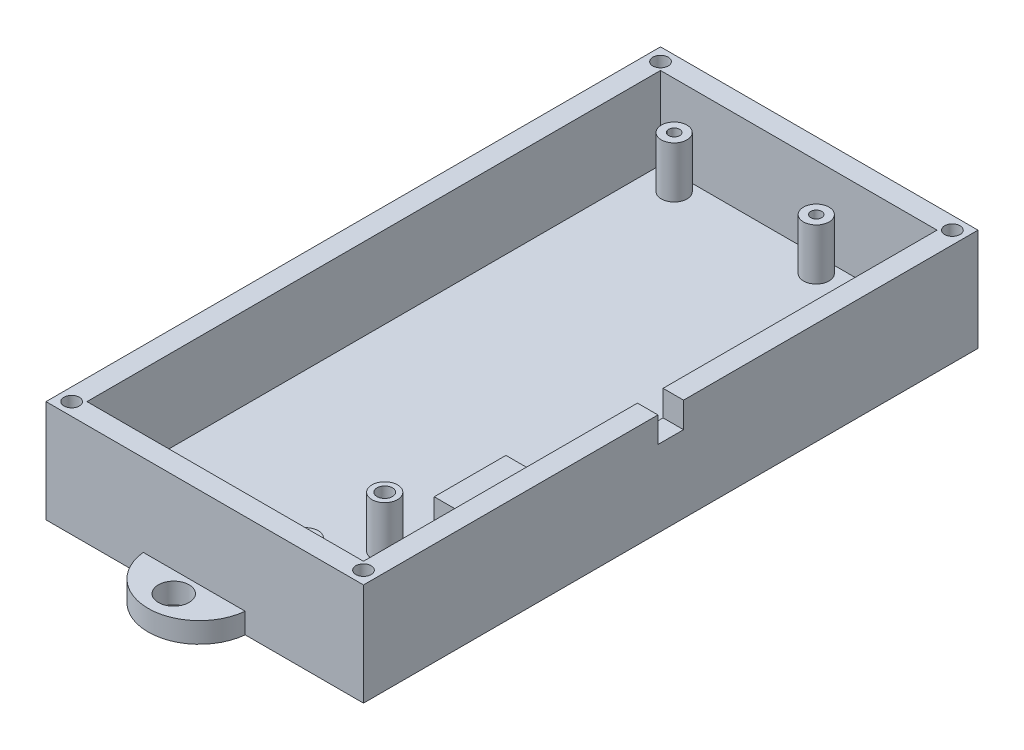
from build123d import *

# Parameters (mm, degrees)
SKETCH1_W                      = 60
SKETCH1_H                      = 118
BOSS_EXTRUDE1_DEPTH            = 4
SKETCH2_R                      = 2.5
BOSS_EXTRUDE2_DEPTH            = 10
SKETCH3_R                      = 1.075
SKETCH3_R_2                    = 1.5
CUT_EXTRUDE1_DEPTH             = 8
SKETCH4_W                      = 14
SKETCH4_H                      = 14
BOSS_EXTRUDE3_DEPTH            = 5
SKETCH5_W                      = 60
SKETCH5_H                      = 118
SKETCH5_W_2                    = 54
SKETCH5_H_2                    = 112
BOSS_EXTRUDE4_DEPTH            = 16
SKETCH10_W                     = 62
SKETCH10_H                     = 120
SKETCH10_W_2                   = 60
SKETCH10_H_2                   = 118
BOSS_EXTRUDE7_DEPTH            = 20
SKETCH6_R                      = 1.5
CUT_EXTRUDE2_DEPTH             = 10
CUT_EXTRUDE3_REACH             = 63
SKETCH7_W                      = 5
SKETCH7_H                      = 10
CUT_EXTRUDE3_DIRECTION_2_DEPTH = 10
SKETCH8_R                      = 3
BOSS_EXTRUDE5_DEPTH            = 4


with BuildPart() as part:
    # Sketch1 → Boss-Extrude1 (new body)
    with BuildSketch(Plane(origin=(0, 0, 0), x_dir=(1, 0, 0), z_dir=(0, 1, 0))):
        Rectangle(SKETCH1_W, SKETCH1_H)
    extrude(amount=BOSS_EXTRUDE1_DEPTH)

    # Sketch2 → Boss-Extrude2 (add)
    with BuildSketch(Plane(origin=(0, 4, 0), x_dir=(1, 0, 0), z_dir=(0, 1, 0))):
        with Locations((-21.18316549, 52.849664436)):
            Circle(SKETCH2_R)
        with Locations((6.566834506, 52.850079416)):
            Circle(SKETCH2_R)
        with Locations((-21.449381738, -52.75)):
            Circle(SKETCH2_R)
        with Locations((6.300617416, -52.75)):
            Circle(SKETCH2_R)
        with Locations((11.396968897, -36.250000429)):
            Circle(SKETCH2_R)
        with Locations((11.400617416, -51.75)):
            Circle(SKETCH2_R)
    extrude(amount=BOSS_EXTRUDE2_DEPTH)

    # Sketch3 → Cut-Extrude1 (cut)
    with BuildSketch(Plane(origin=(0, 14, 0), x_dir=(1, 0, 0), z_dir=(0, 1, 0))):
        with Locations((-21.18316549, 52.849664436)):
            Circle(SKETCH3_R)
        with Locations((6.566834506, 52.850079416)):
            Circle(SKETCH3_R)
        with Locations((11.396968897, -36.250000429)):
            Circle(SKETCH3_R_2)
        with Locations((11.400617416, -51.75)):
            Circle(SKETCH3_R_2)
        with Locations((6.300617416, -52.75)):
            Circle(SKETCH3_R)
        with Locations((-21.449381738, -52.75)):
            Circle(SKETCH3_R)
    extrude(amount=-CUT_EXTRUDE1_DEPTH, mode=Mode.SUBTRACT)

    # Sketch4 → Boss-Extrude3 (add)
    with BuildSketch(Plane(origin=(0, 4, 0), x_dir=(1, 0, 0), z_dir=(0, 1, 0))):
        with Locations((19, -20.184694787)):
            Rectangle(SKETCH4_W, SKETCH4_H)
    extrude(amount=BOSS_EXTRUDE3_DEPTH)

    # Sketch5 → Boss-Extrude4 (add)
    with BuildSketch(Plane(origin=(0, 4, 0), x_dir=(1, 0, 0), z_dir=(0, 1, 0))):
        Rectangle(SKETCH5_W, SKETCH5_H)
        Rectangle(SKETCH5_W_2, SKETCH5_H_2, mode=Mode.SUBTRACT)
    extrude(amount=BOSS_EXTRUDE4_DEPTH)

    # Sketch10 → Boss-Extrude7 (add)
    with BuildSketch(Plane(origin=(0, 0, 0), x_dir=(1, 0, 0), z_dir=(0, 1, 0))):
        Rectangle(SKETCH10_W, SKETCH10_H)
        Rectangle(SKETCH10_W_2, SKETCH10_H_2, mode=Mode.SUBTRACT)
    extrude(amount=BOSS_EXTRUDE7_DEPTH)

    # Sketch6 → Cut-Extrude2 (cut)
    with BuildSketch(Plane(origin=(0, 20, 0), x_dir=(1, 0, 0), z_dir=(0, 1, 0))):
        with Locations((-28.5, 57.5)):
            Circle(SKETCH6_R)
        with Locations((28.5, 57.5)):
            Circle(SKETCH6_R)
        with Locations((-28.5, -57.5)):
            Circle(SKETCH6_R)
        with Locations((28.5, -57.5)):
            Circle(SKETCH6_R)
    extrude(amount=-CUT_EXTRUDE2_DEPTH, mode=Mode.SUBTRACT)

    # Sketch7 → Cut-Extrude3 (cut, up to next)
    with BuildSketch(Plane(origin=(30, 0, 0), x_dir=(0, 0, -1), z_dir=(1, 0, 0)), mode=Mode.PRIVATE) as cut_extrude3_sk1:
        with Locations((0, 20)):
            Rectangle(SKETCH7_W, SKETCH7_H)
    cut_extrude3_tool1 = extrude(cut_extrude3_sk1.sketch, amount=-CUT_EXTRUDE3_REACH, mode=Mode.PRIVATE) & part.part
    add(cut_extrude3_tool1.solids().sort_by_distance((30, 20, 0))[0], mode=Mode.SUBTRACT)

    # Sketch7 → Cut-Extrude3 direction 2 (cut)
    with BuildSketch(Plane(origin=(30, 0, 0), x_dir=(0, 0, -1), z_dir=(1, 0, 0))):
        with Locations((0, 20)):
            Rectangle(SKETCH7_W, SKETCH7_H)
    extrude(amount=CUT_EXTRUDE3_DIRECTION_2_DEPTH, mode=Mode.SUBTRACT)

    # Sketch8 → Boss-Extrude5 (add)
    with BuildSketch(Plane(origin=(0, 0, 0), x_dir=(1, 0, 0), z_dir=(0, 1, 0))):
        with BuildLine():
            Line((10, 59), (-10, 59))
            ThreePointArc((-10, 59), (0, 69), (10, 59))
        make_face()
        with Locations((0, 64)):
            Circle(SKETCH8_R, mode=Mode.SUBTRACT)
        with BuildLine():
            Line((7.946608606, -59.003318261), (-12.053391394, -59.003318261))
            ThreePointArc((-12.053391394, -59.003318261), (-2.053391394, -69.003318261), (7.946608606, -59.003318261))
        make_face()
        with Locations((-2.053391394, -64.003318261)):
            Circle(SKETCH8_R, mode=Mode.SUBTRACT)
    extrude(amount=BOSS_EXTRUDE5_DEPTH)


solid = part.part
